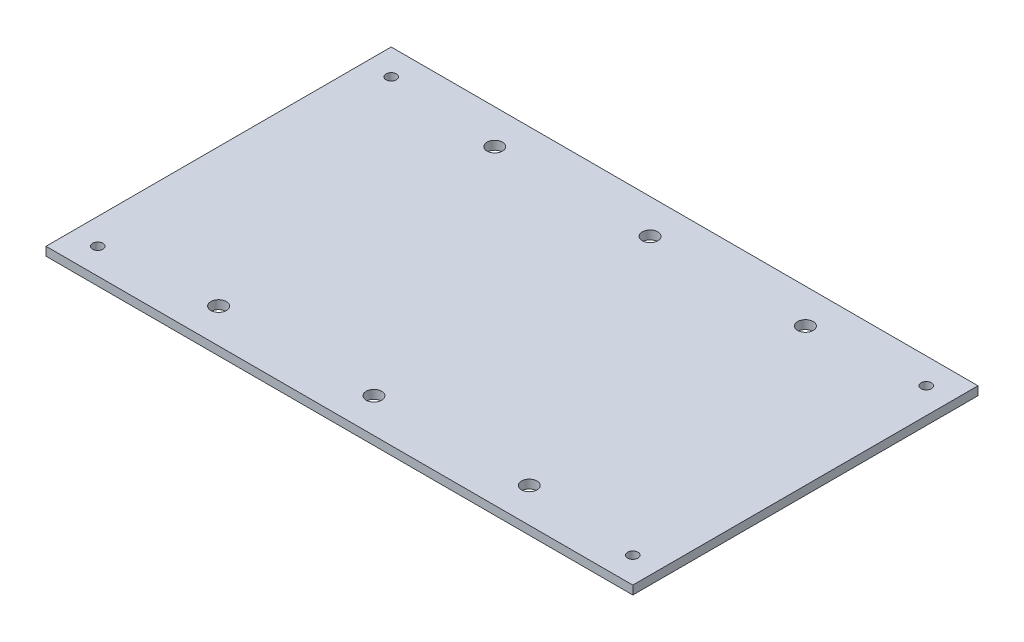
from build123d import *

# Parameters (mm, degrees)
SKETCH1_W           = 340
SKETCH1_H           = 200
SKETCH1_R           = 3
SKETCH1_R_2         = 4.5
BOSS_EXTRUDE1_DEPTH = 5


with BuildPart() as part:
    # Sketch1 → Boss-Extrude1 (new body)
    with BuildSketch(Plane(origin=(0, 0, 0), x_dir=(1, 0, 0), z_dir=(0, 1, 0))):
        Rectangle(SKETCH1_W, SKETCH1_H)
        with Locations((155, 85)):
            Circle(SKETCH1_R, mode=Mode.SUBTRACT)
        with Locations((-155, 85)):
            Circle(SKETCH1_R, mode=Mode.SUBTRACT)
        with Locations((-155, -85)):
            Circle(SKETCH1_R, mode=Mode.SUBTRACT)
        with Locations((155, -85)):
            Circle(SKETCH1_R, mode=Mode.SUBTRACT)
        with Locations((0, 80)):
            Circle(SKETCH1_R_2, mode=Mode.SUBTRACT)
        with Locations((0, -80)):
            Circle(SKETCH1_R_2, mode=Mode.SUBTRACT)
        with Locations((90, 80)):
            Circle(SKETCH1_R_2, mode=Mode.SUBTRACT)
        with Locations((90, -80)):
            Circle(SKETCH1_R_2, mode=Mode.SUBTRACT)
        with Locations((-90, -80)):
            Circle(SKETCH1_R_2, mode=Mode.SUBTRACT)
        with Locations((-90, 80)):
            Circle(SKETCH1_R_2, mode=Mode.SUBTRACT)
    extrude(amount=BOSS_EXTRUDE1_DEPTH)


solid = part.part
